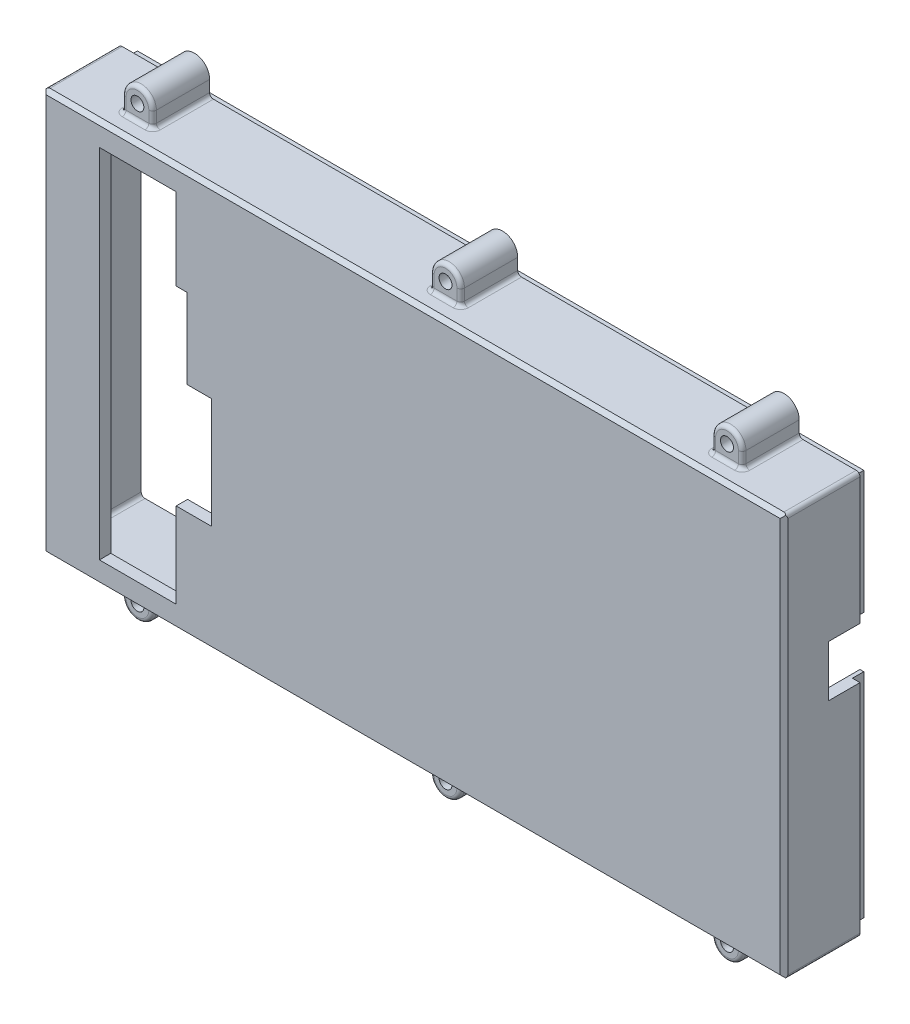
from build123d import *

# Parameters (mm, degrees)
BOSS_EXTRUDE2_DEPTH  = 20
SKETCH3_W            = 189.15
SKETCH3_H            = 100
CUT_EXTRUDE2_DEPTH   = 17
SKETCH22_W           = 195.15
SKETCH22_H           = 20
CUT_EXTRUDE8_DEPTH   = 5
CHAMFER1_SIZE        = 1
M3_CLEARANCE_HOLE1_D = 3.4
SKETCH13_W           = 191.15
SKETCH13_H           = 102
SKETCH13_W_2         = 189.15
SKETCH13_H_2         = 100
BOSS_EXTRUDE3_DEPTH  = 20
SKETCH18_W           = 14.5
SKETCH18_H           = 13.5
CUT_EXTRUDE4_DEPTH   = 20
FILLET1_R            = 1
CUT_EXTRUDE7_DEPTH   = 10


with BuildPart() as part:
    # Sketch1 → Boss-Extrude2 (new body)
    with BuildSketch(Plane.XY):
        with BuildLine():
            Line((-85.075, -57), (-85.075, -53))
            Line((-85.075, -53), (-101.075, -53))
            Line((-101.075, -53), (-101.075, 53))
            Line((-101.075, 53), (-85.075, 53))
            Line((-85.075, 53), (-85.075, 57))
            ThreePointArc((-85.075, 57), (-81.075, 61), (-77.075, 57))
            Line((-77.075, 57), (-77.075, 53))
            Line((-77.075, 53), (-4, 53))
            Line((-4, 53), (-4, 57))
            ThreePointArc((-4, 57), (0, 61), (4, 57))
            Line((4, 57), (4, 53))
            Line((4, 53), (70.075, 53))
            Line((70.075, 53), (70.075, 57))
            ThreePointArc((70.075, 57), (74.075, 61), (78.075, 57))
            Line((78.075, 57), (78.075, 53))
            Line((78.075, 53), (94.075, 53))
            Line((94.075, 53), (94.075, -53))
            Line((94.075, -53), (78.075, -53))
            Line((78.075, -53), (78.075, -57))
            ThreePointArc((78.075, -57), (74.075, -61), (70.075, -57))
            Line((70.075, -57), (70.075, -53))
            Line((70.075, -53), (4, -53))
            Line((4, -53), (4, -57))
            ThreePointArc((4, -57), (0, -61), (-4, -57))
            Line((-4, -57), (-4, -53))
            Line((-4, -53), (-77.075, -53))
            Line((-77.075, -53), (-77.075, -57))
            ThreePointArc((-77.075, -57), (-81.075, -61), (-85.075, -57))
        make_face()
    extrude(amount=BOSS_EXTRUDE2_DEPTH)

    # Sketch3 → Cut-Extrude2 (cut)
    with BuildSketch(Plane(origin=(0, 0, 0), x_dir=(-1, 0, 0), z_dir=(0, 0, -1))):
        with Locations((3.5, 0)):
            Rectangle(SKETCH3_W, SKETCH3_H)
    extrude(amount=-CUT_EXTRUDE2_DEPTH, mode=Mode.SUBTRACT)

    # Sketch22 → Cut-Extrude8 (cut)
    with BuildSketch(Plane.XY.offset(20)):
        with Locations((-3.5, -63)):
            Rectangle(SKETCH22_W, SKETCH22_H)
        with Locations((-3.5, 63)):
            Rectangle(SKETCH22_W, SKETCH22_H)
    extrude(amount=-CUT_EXTRUDE8_DEPTH, mode=Mode.SUBTRACT)

    # Chamfer1
    chamfer1_edges = [part.edges().sort_by_distance(p)[0] for p in [
        (-3.5, -53, 20),
        (94.075, 0, 20),
        (-3.5, 53, 20),
        (-101.075, 0, 20),
    ]]
    chamfer(chamfer1_edges, length=CHAMFER1_SIZE)

    # M3 Clearance Hole1 (through all)
    with Locations(Plane(origin=(0, 0, 0), x_dir=(-1, 0, 0), z_dir=(0, 0, -1))):
        with Locations((81.075, -57), (0, -57), (81.075, 57), (0, 57), (-74.075, 57), (-74.075, -57)):
            Hole(M3_CLEARANCE_HOLE1_D / 2)

    # Sketch13 → Boss-Extrude3 (add)
    with BuildSketch(Plane(origin=(0, 0, 17), x_dir=(-1, 0, 0), z_dir=(0, 0, -1))):
        with Locations((3.5, 0)):
            Rectangle(SKETCH13_W, SKETCH13_H)
        with Locations((3.5, 0)):
            Rectangle(SKETCH13_W_2, SKETCH13_H_2, mode=Mode.SUBTRACT)
    extrude(amount=BOSS_EXTRUDE3_DEPTH)

    # Sketch18 → Cut-Extrude4 (cut)
    with BuildSketch(Plane(origin=(94.075, 0, 0), x_dir=(0, 0, -1), z_dir=(1, 0, 0))):
        with Locations((-1, 11.86)):
            Rectangle(SKETCH18_W, SKETCH18_H)
    extrude(amount=-CUT_EXTRUDE4_DEPTH, mode=Mode.SUBTRACT)

    # Fillet1
    fillet1_edges = [part.edges().sort_by_distance(p)[0] for p in [
        (0, -53, 15),
        (74.075, -53, 15),
        (-85.075, 53, 7.5),
        (-77.075, 53, 7.5),
        (-4, 53, 7.5),
        (4, 53, 7.5),
        (70.075, 53, 7.5),
        (78.075, 53, 7.5),
        (74.075, 53, 15),
        (0, 53, 15),
        (-81.075, 53, 15),
        (78.075, 55, 15),
        (74.075, 61, 15),
        (70.075, 55, 15),
        (4, 55, 15),
        (0, 61, 15),
        (-4, 55, 15),
        (-77.075, 55, 15),
        (-81.075, 61, 15),
        (-85.075, 55, 15),
        (94.075, 53, 9.5),
        (94.075, -53, 9.5),
        (-101.075, -53, 9.5),
        (-101.075, 53, 9.5),
        (91.075, 50, 7),
        (91.075, -50, 7),
        (-98.075, -50, 7),
        (-98.075, 50, 7),
        (78.075, -53, 7.5),
        (70.075, -53, 7.5),
        (4, -53, 7.5),
        (-4, -53, 7.5),
        (-77.075, -53, 7.5),
        (-85.075, -53, 7.5),
        (-81.075, -61, 15),
        (-85.075, -55, 15),
        (-77.075, -55, 15),
        (0, -61, 15),
        (-4, -55, 15),
        (4, -55, 15),
        (74.075, -61, 15),
        (70.075, -55, 15),
        (78.075, -55, 15),
        (-81.075, -53, 15),
    ]]
    fillet(fillet1_edges, radius=FILLET1_R)

    # Sketch21 → Cut-Extrude7 (cut)
    with BuildSketch(Plane(origin=(0, 0, 17), x_dir=(-1, 0, 0), z_dir=(0, 0, -1))):
        Polygon((86.075, -47), (65.875, -47), (65.875, -24.6), (56.575, -24.6), (56.575, 4.5), (63.075, 4.5), (63.075, 25.5), (65.875, 25.5), (65.875, 47), (86.075, 47), align=None)
    extrude(amount=-CUT_EXTRUDE7_DEPTH, mode=Mode.SUBTRACT)


solid = part.part
